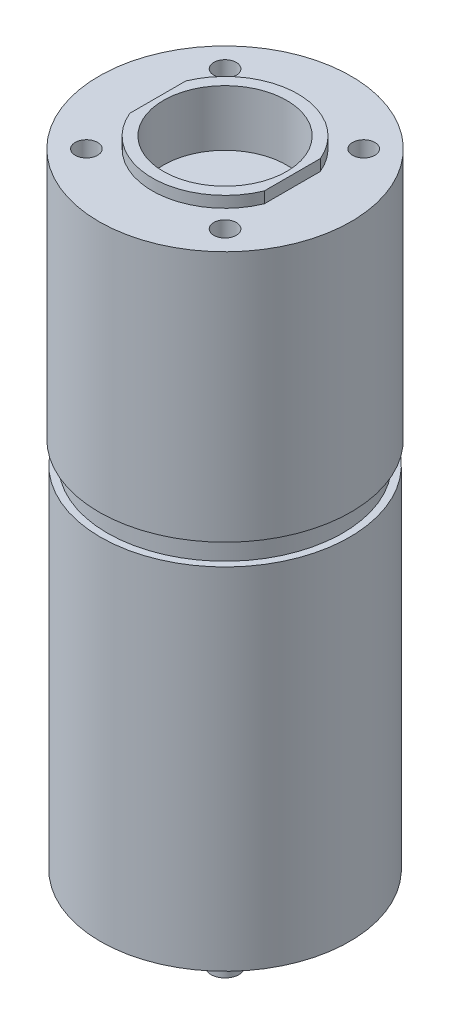
from build123d import *

# Parameters (mm, degrees)
SKETCH2_R          = 11
CUT_EXTRUDE1_DEPTH = 10
SKETCH3_W          = 5
SKETCH3_H          = 33.574223154
CUT_EXTRUDE2_DEPTH = 2
SKETCH4_R          = 2
CUT_EXTRUDE3_DEPTH = 9


with BuildPart() as part:
    # Sketch1 → Revolve1 (revolve)
    with BuildSketch(Plane.XY):
        Polygon((0, 0), (-13, 0), (-13, -2), (-22.5, -2), (-22.5, -46.9), (-21, -46.9), (-21, -50.9), (-22.25, -50.9), (-22.25, -113.4), (-6, -113.4), (-6, -118.4), (-2.5, -118.4), (-2.5, -128.4), (0, -128.4), align=None)
    revolve(axis=Axis((0, 0, 0), (0, -1, 0)))

    # Sketch2 → Cut-Extrude1 (cut)
    with BuildSketch(Plane(origin=(0, 0, 0), x_dir=(1, 0, 0), z_dir=(0, 1, 0))):
        Circle(SKETCH2_R)
    extrude(amount=-CUT_EXTRUDE1_DEPTH, mode=Mode.SUBTRACT)

    # Sketch3 → Cut-Extrude2 (cut)
    with BuildSketch(Plane(origin=(0, 0, 0), x_dir=(1, 0, 0), z_dir=(0, 1, 0))):
        with Locations((-14.5, 0)):
            Rectangle(SKETCH3_W, SKETCH3_H)
        with Locations((14.5, 0)):
            Rectangle(SKETCH3_W, SKETCH3_H)
    extrude(amount=-CUT_EXTRUDE2_DEPTH, mode=Mode.SUBTRACT)

    # Sketch4 → Cut-Extrude3 (cut)
    with BuildSketch(Plane(origin=(0, -2, 0), x_dir=(1, 0, 0), z_dir=(0, 1, 0))):
        with Locations((-12.374368671, 12.374368671)):
            Circle(SKETCH4_R)
        with Locations((12.374368671, 12.374368671)):
            Circle(SKETCH4_R)
        with Locations((12.374368671, -12.374368671)):
            Circle(SKETCH4_R)
        with Locations((-12.374368671, -12.374368671)):
            Circle(SKETCH4_R)
    extrude(amount=-CUT_EXTRUDE3_DEPTH, mode=Mode.SUBTRACT)


solid = part.part
